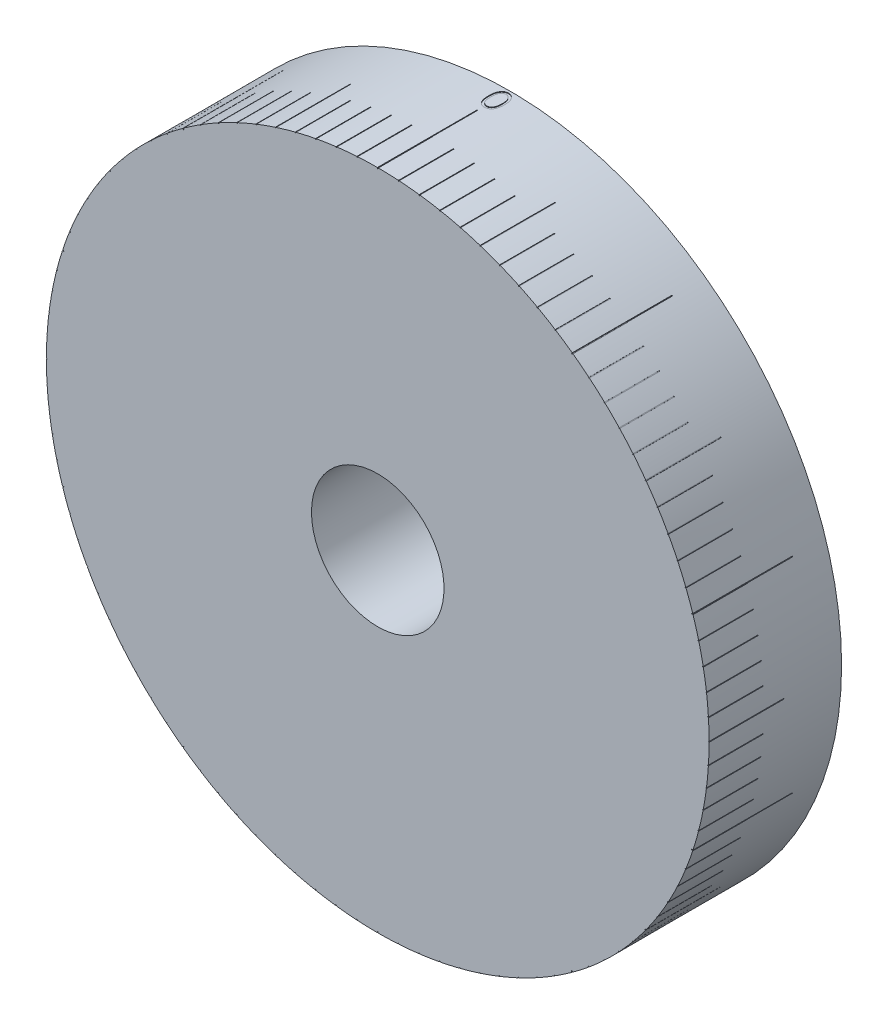
from build123d import *

# Parameters (mm, degrees)
SKICA1_W                      = 20
SKICA1_H                      = 50
ODEBRAT_VYSUNUT_M1_DEPTH      = 0.2
KRUHOV_POLE17_COUNT           = 10
SKICA7_R                      = 44.886325665
SKICA7_R_2                    = 20.446670217
ODEBRAT_VYSUNUT_M2_DEPTH      = 15
SKICA8_R                      = 10
ODEBRAT_VYSUNUT_M3_DEPTH      = 16.0000001
ODEBRAT_VYSUNUT_M3_DEPTH_BACK = 15
SKICA12_W                     = 11.298764015
SKICA12_H                     = 0.1
ODEBRAT_VYSUNUT_M4_DEPTH      = 0.1
KRUHOV_POLE19_COUNT           = 10
SKICA13_W                     = 8.267889974
SKICA13_H                     = 0.1
ODEBRAT_VYSUNUT_M5_DEPTH      = 0.1
KRUHOV_POLE21_COUNT           = 100
ODEBRAT_VYSUNUT_M7_DEPTH      = 0.1


with BuildPart() as part:
    # Skica1 → Rotovat1 (revolve)
    with BuildSketch(Plane(origin=(0, 0, 0), x_dir=(0, 0, -1), z_dir=(1, 0, 0)), mode=Mode.PRIVATE) as rotovat1_sk:
        with Locations((10, 25)):
            Rectangle(SKICA1_W, SKICA1_H)
    revolve(rotovat1_sk.sketch.rotate(Axis((0, 0, 0), (0, 0, -1)), 90), axis=Axis((0, 0, 0), (0, 0, -1)))  # turned: the seam where the file's is

    # Skica5 → Odebrat vysunutím1 (cut)
    with BuildSketch(Plane(origin=(0, 50, 0), x_dir=(1, 0, 0), z_dir=(0, 1, 0))):
        with BuildLine():
            Line((-0.05, 0), (-0.05, 15))
            ThreePointArc((-0.05, 15), (0, 15.05), (0.05, 15))
            Line((0.05, 15), (0.05, 0))
            ThreePointArc((0.05, 0), (0, -0.05), (-0.05, 0))
        make_face()
    odebrat_vysunut_m1 = extrude(amount=-ODEBRAT_VYSUNUT_M1_DEPTH, mode=Mode.SUBTRACT)

    # Kruhové pole17: Odebrat vysunutím1 ×10 about axis
    kruhov_pole17_axis = Axis((0, 0, 0), (0, 0, 1))
    for i in range(1, KRUHOV_POLE17_COUNT):
        add(odebrat_vysunut_m1.rotate(kruhov_pole17_axis, i * 360 / KRUHOV_POLE17_COUNT), mode=Mode.SUBTRACT)

    # Skica7 → Odebrat vysunutím2 (cut)
    with BuildSketch(Plane(origin=(0, 0, -20), x_dir=(-1, 0, 0), z_dir=(0, 0, -1))):
        Circle(SKICA7_R)
        Circle(SKICA7_R_2, mode=Mode.SUBTRACT)
    extrude(amount=-ODEBRAT_VYSUNUT_M2_DEPTH, mode=Mode.SUBTRACT)

    # Skica8 → Odebrat vysunutím3 (cut, two sides)
    with BuildSketch(Plane(origin=(0, 0, -5), x_dir=(-1, 0, 0), z_dir=(0, 0, -1))) as odebrat_vysunut_m3_sk:
        Circle(SKICA8_R)
    extrude(amount=ODEBRAT_VYSUNUT_M3_DEPTH, mode=Mode.SUBTRACT)
    extrude(odebrat_vysunut_m3_sk.sketch, amount=-ODEBRAT_VYSUNUT_M3_DEPTH_BACK, mode=Mode.SUBTRACT)

    # Skica12 → Odebrat vysunutím4 (cut)
    with BuildSketch(Plane(origin=(-15.450849719, 47.552825815, 0), x_dir=(0, 0, 1), z_dir=(0.309016994, -0.951056516, 0))):
        with Locations((-5.649382008, -0.05)):
            Rectangle(SKICA12_W, SKICA12_H)
    odebrat_vysunut_m4 = extrude(amount=ODEBRAT_VYSUNUT_M4_DEPTH, mode=Mode.SUBTRACT)

    # Kruhové pole19: Odebrat vysunutím4 ×10 about axis
    kruhov_pole19_axis = Axis((0, 0, 0), (0, 0, 1))
    for i in range(1, KRUHOV_POLE19_COUNT):
        add(odebrat_vysunut_m4.rotate(kruhov_pole19_axis, i * 360 / KRUHOV_POLE19_COUNT), mode=Mode.SUBTRACT)

    # Skica13 → Odebrat vysunutím5 (cut)
    with BuildSketch(Plane(origin=(-18.325061336, 46.520878399, 0), x_dir=(0, 0, 1), z_dir=(-0.366501227, 0.930417568, 0))):
        with Locations((-4.133944987, -0.05)):
            Rectangle(SKICA13_W, SKICA13_H)
    odebrat_vysunut_m5 = extrude(amount=-ODEBRAT_VYSUNUT_M5_DEPTH, mode=Mode.SUBTRACT)

    # Kruhové pole21: Odebrat vysunutím5 ×100 about axis
    kruhov_pole21_axis = Axis((0, 0, 0), (0, 0, 1))
    for i in range(1, KRUHOV_POLE21_COUNT):
        add(odebrat_vysunut_m5.rotate(kruhov_pole21_axis, i * 360 / KRUHOV_POLE21_COUNT), mode=Mode.SUBTRACT)

    # Skica15 → Odebrat vysunutím7 (cut)
    with BuildSketch(Plane(origin=(0, 50, 0), x_dir=(1, 0, 0), z_dir=(0, 1, 0))):
        with BuildLine():
            add(Edge.make_bspline(
                [(-1.043081982, 17.777318579), (-1.042753964, 17.833415966), (-1.042116784, 17.942385951), (-1.035028363, 18.101170593), (-1.02325302, 18.250130882), (-1.007115648, 18.389273948), (-0.987477667, 18.518635712), (-0.961262181, 18.637870469), (-0.931449378, 18.747530076), (-0.896896932, 18.847972125), (-0.857909143, 18.940549828), (-0.815474883, 19.026975029), (-0.767910088, 19.107116961), (-0.717933175, 19.182254752), (-0.663521104, 19.251158446), (-0.606222313, 19.314801109), (-0.543800437, 19.371711859), (-0.478377429, 19.423558162), (-0.409360964, 19.469007633), (-0.338718298, 19.509040372), (-0.265963192, 19.543240239), (-0.190897009, 19.570130675), (-0.114194451, 19.592341522), (-0.035587385, 19.60753047), (0.045053979, 19.617087378), (0.099485414, 19.618001046), (0.127090294, 19.618464412)],
                knots=[0, 0, 0, 0, 1.646270934, 3.197905019, 4.663502075, 6.030701355, 7.308322542, 8.50163776, 9.611534131, 10.641858119, 11.616356847, 12.558055219, 13.465016945, 14.349605745, 15.204443733, 16.039544428, 16.859896111, 17.680448484, 18.487036065, 19.28249412, 20.06191084, 20.843045899, 21.620316918, 22.403196591, 23.190181807, 24, 24, 24, 24], degree=3))
            add(Edge.make_bspline(
                [(0.127090294, 19.618464412), (0.154925772, 19.617976597), (0.210281781, 19.617006486), (0.292122156, 19.607682543), (0.372071838, 19.59221142), (0.449789977, 19.570290446), (0.525914963, 19.543094769), (0.599851371, 19.509007652), (0.672058453, 19.469328785), (0.74138874, 19.422704907), (0.808603356, 19.370722631), (0.872051319, 19.311959962), (0.931738404, 19.247010243), (0.98841371, 19.176568379), (1.040469307, 19.099283294), (1.090042739, 19.016499185), (1.134414775, 18.92676832), (1.17714945, 18.831587852), (1.214036437, 18.728324193), (1.247302682, 18.617559433), (1.274181651, 18.497985246), (1.296570923, 18.370229), (1.313915819, 18.233821517), (1.326548461, 18.089055202), (1.333221546, 17.935834811), (1.334478247, 17.831076962), (1.335123146, 17.777318579)],
                knots=[0, 0, 0, 0, 0.810914788, 1.612654377, 2.396697861, 3.181598691, 3.963628158, 4.749916497, 5.551656086, 6.361998678, 7.18212741, 8.025565596, 8.878627764, 9.750805457, 10.657531673, 11.591944965, 12.560506719, 13.57287815, 14.630710178, 15.753379473, 16.941251878, 18.199788006, 19.531962791, 20.947069417, 22.433333509, 24, 24, 24, 24], degree=3))
            add(Edge.make_bspline(
                [(1.335123146, 17.777318579), (1.334471562, 17.723794671), (1.333201976, 17.619505519), (1.326623269, 17.466974544), (1.313664638, 17.3229765), (1.29745465, 17.187166038), (1.275003687, 17.060108419), (1.24739852, 16.941363971), (1.216748198, 16.830419899), (1.178913404, 16.728185087), (1.137502693, 16.633233364), (1.092447497, 16.544566216), (1.044177671, 16.461399923), (0.991588926, 16.384400176), (0.935535513, 16.313021519), (0.874817724, 16.248523897), (0.811147139, 16.189353225), (0.743734723, 16.136701597), (0.673323172, 16.090616793), (0.601364095, 16.049402942), (0.526580712, 16.016170247), (0.450667759, 15.987635206), (0.372539393, 15.965834754), (0.292293002, 15.950760899), (0.210336766, 15.94018905), (0.154935201, 15.939382571), (0.127090294, 15.938977233)],
                knots=[0, 0, 0, 0, 1.561518951, 3.042555995, 4.452378317, 5.7783523, 7.031515105, 8.214008947, 9.334062868, 10.386615937, 11.391082383, 12.354592575, 13.286541444, 14.194233754, 15.072674879, 15.931287219, 16.775624067, 17.606195743, 18.42308326, 19.229000347, 20.022332153, 20.807536673, 21.593273796, 22.3848459, 23.188221202, 24, 24, 24, 24], degree=3))
            add(Edge.make_bspline(
                [(0.127090294, 15.938977233), (0.09948618, 15.939443588), (0.045056255, 15.94036315), (-0.03559617, 15.949876881), (-0.113878614, 15.965172385), (-0.190177368, 15.986588989), (-0.264883883, 16.012803825), (-0.33698017, 16.046957509), (-0.407267853, 16.086291578), (-0.475559409, 16.131086999), (-0.54057157, 16.182408682), (-0.602670176, 16.239172971), (-0.660295195, 16.302796382), (-0.71392929, 16.372274305), (-0.764903379, 16.446967548), (-0.811792752, 16.527895921), (-0.855163606, 16.614738531), (-0.894807097, 16.708056442), (-0.92995576, 16.80921137), (-0.961003468, 16.919360548), (-0.985517626, 17.039476184), (-1.006500581, 17.168593551), (-1.023424964, 17.307267482), (-1.034979289, 17.45557326), (-1.042120604, 17.613418469), (-1.042755675, 17.721688243), (-1.043081982, 17.777318579)],
                knots=[0, 0, 0, 0, 0.810891512, 1.598919785, 2.382837074, 3.152667961, 3.926044502, 4.706494248, 5.493654104, 6.291793342, 7.103789334, 7.925228297, 8.761435821, 9.622817696, 10.50288917, 11.416980706, 12.369136599, 13.353924996, 14.394355917, 15.514179734, 16.714354668, 17.994756427, 19.357759367, 20.818452758, 22.365282078, 24, 24, 24, 24], degree=3))
        make_face()
        with BuildLine():
            add(Edge.make_bspline(
                [(-0.728979418, 17.778720822), (-0.728859971, 17.731972124), (-0.728628147, 17.641242079), (-0.722571947, 17.509398818), (-0.714321715, 17.386428489), (-0.703680418, 17.272174952), (-0.687877469, 17.16702494), (-0.670170681, 17.070255257), (-0.648622592, 16.98237802), (-0.623127574, 16.902790209), (-0.594088477, 16.830141141), (-0.562382613, 16.762539925), (-0.52832189, 16.699187989), (-0.49020274, 16.640654381), (-0.448687676, 16.586748217), (-0.404714417, 16.536515384), (-0.356641833, 16.491718403), (-0.290138091, 16.437991548), (-0.202341616, 16.382472414), (-0.091721161, 16.334126324), (0.02194729, 16.303743868), (0.09909854, 16.299880112), (0.137607121, 16.297951592)],
                knots=[0, 0, 0, 0, 1.459021318, 2.831673884, 4.118529203, 5.306027144, 6.411944654, 7.436330062, 8.375795394, 9.233974572, 10.042671642, 10.816086306, 11.563610507, 12.285937304, 12.993564865, 13.685989202, 14.367179055, 15.041617293, 16.353048772, 17.594441528, 18.799311195, 20, 20, 20, 20], degree=3))
            add(Edge.make_bspline(
                [(0.137607121, 16.297951592), (0.176364792, 16.299549372), (0.253800116, 16.302741635), (0.366933911, 16.333540373), (0.476764181, 16.380009912), (0.562836121, 16.434957417), (0.628318665, 16.487285747), (0.675235655, 16.531900395), (0.718297703, 16.581856262), (0.759139778, 16.635755558), (0.796598854, 16.694628043), (0.830661991, 16.758190618), (0.861745339, 16.826619796), (0.879454385, 16.874389535), (0.888508563, 16.89881297)],
                knots=[0, 0, 0, 0, 1.353760809, 2.704726607, 4.075137775, 5.516104923, 6.260822281, 7.007110065, 7.778089737, 8.566572457, 9.372053459, 10.217411131, 11.088608312, 12, 12, 12, 12], degree=3))
            add(Edge.make_bspline(
                [(0.888508563, 16.89881297), (0.899060331, 16.930042709), (0.920484945, 16.993452473), (0.948096719, 17.091816126), (0.969842118, 17.195018889), (0.989405484, 17.302444006), (1.00275854, 17.414883707), (1.013506353, 17.531990091), (1.01983704, 17.653851453), (1.020621791, 17.736646445), (1.021020582, 17.778720822)],
                knots=[0, 0, 0, 0, 0.884706709, 1.796334032, 2.740027952, 3.714592787, 4.726048262, 5.777819803, 6.87074269, 8, 8, 8, 8], degree=3))
            add(Edge.make_bspline(
                [(1.021020582, 17.778720822), (1.020470393, 17.820788395), (1.019394105, 17.90308156), (1.015280118, 18.02359974), (1.004656543, 18.138067501), (0.992857424, 18.246977974), (0.975460203, 18.349728277), (0.956702396, 18.447178582), (0.931501184, 18.538121607), (0.904581409, 18.623981188), (0.873771014, 18.703781843), (0.839855279, 18.777895629), (0.80363352, 18.846680354), (0.76429128, 18.909947296), (0.722295597, 18.967979838), (0.676538048, 19.019614433), (0.628833675, 19.066451401), (0.562016489, 19.11991397), (0.474542199, 19.174425666), (0.365696552, 19.224591426), (0.252425908, 19.253399718), (0.175852454, 19.257461405), (0.137607121, 19.259490053)],
                knots=[0, 0, 0, 0, 1.31362396, 2.569729283, 3.763502607, 4.902122613, 5.988968491, 7.01645872, 7.998833611, 8.933434873, 9.825090667, 10.667526885, 11.477055099, 12.250526234, 12.991942729, 13.710640831, 14.402115721, 15.076753259, 16.378508321, 17.609869233, 18.806226677, 20, 20, 20, 20], degree=3))
            add(Edge.make_bspline(
                [(0.137607121, 19.259490053), (0.098896529, 19.257458606), (0.021404823, 19.253392012), (-0.093043132, 19.224698759), (-0.202747483, 19.174685793), (-0.289990458, 19.11973342), (-0.356854244, 19.067395109), (-0.403936938, 19.022008655), (-0.44808311, 18.9723624), (-0.48875081, 18.917960486), (-0.526840093, 18.859495118), (-0.561821106, 18.796506354), (-0.593338436, 18.728674989), (-0.622422972, 18.656058554), (-0.64799576, 18.57647761), (-0.669089723, 18.488708616), (-0.688576776, 18.392246724), (-0.702372045, 18.286527216), (-0.714635801, 18.172245063), (-0.722517149, 18.048967745), (-0.728648406, 17.916903364), (-0.728866871, 17.825704206), (-0.728979418, 17.778720822)],
                knots=[0, 0, 0, 0, 1.207732386, 2.417664972, 3.655092373, 4.956220595, 5.625982001, 6.301752483, 6.994047911, 7.697131622, 8.419323945, 9.170223765, 9.943494443, 10.752040957, 11.610060368, 12.549350801, 13.567764191, 14.679664412, 15.874934091, 17.154273443, 18.533957287, 20, 20, 20, 20], degree=3))
        make_face(mode=Mode.SUBTRACT)
    extrude(amount=-ODEBRAT_VYSUNUT_M7_DEPTH, mode=Mode.SUBTRACT)


solid = part.part
